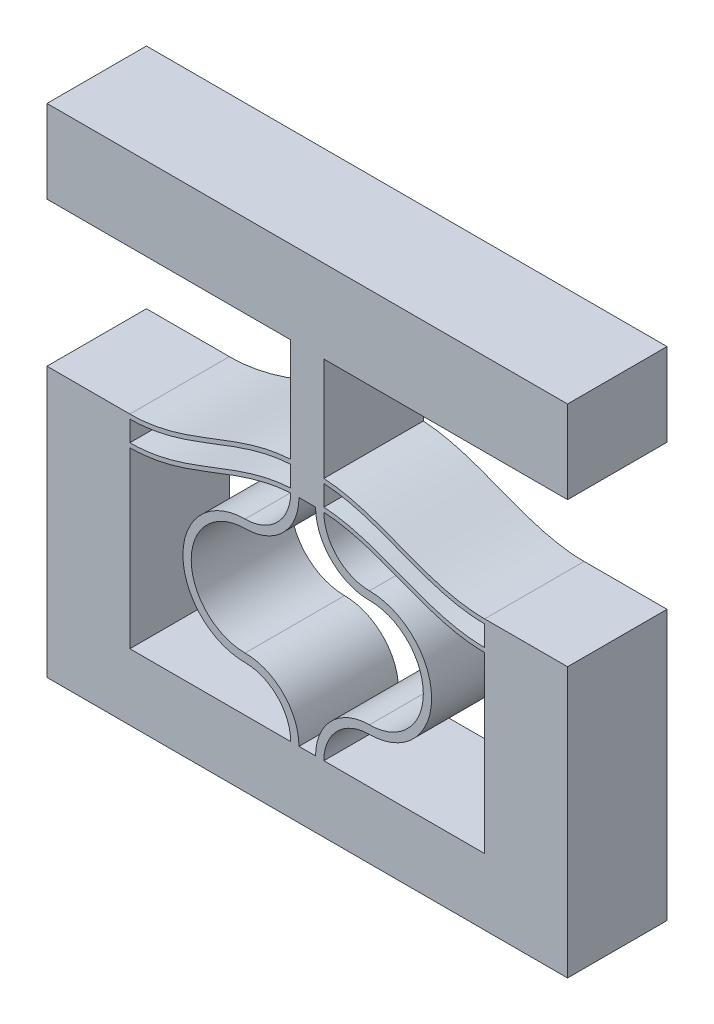
from build123d import *

# Parameters (mm, degrees)
BOSS_EXTRUDE1_DEPTH = 6
SKETCH4_W           = 1.000079602
SKETCH4_H           = 6
BOSS_EXTRUDE2_DEPTH = 5
SKETCH7_W           = 6
SKETCH7_H           = 7.985204536
SKETCH7_H_2         = 4
BOSS_EXTRUDE3_DEPTH = 0.5
SKETCH8_W           = 31.399999662
SKETCH8_H           = 5.000000005
BOSS_EXTRUDE4_DEPTH = 6


with BuildPart() as part:
    # Sketch1 → Boss-Extrude1 (new body)
    with BuildSketch(Plane.XY):
        with BuildLine():
            add(Edge.make_bspline(
                [(10.700039975, 14.745204536), (10.770772559, 14.741026808), (11.036928883, 14.722362813), (11.497122592, 14.671037325), (12.289279781, 14.528352814), (13.186428125, 14.281886639), (13.972953946, 14.012479628), (14.659814487, 13.755888369), (15.208666695, 13.545451258), (15.665563716, 13.368818224), (16.123450769, 13.194753096), (16.65208653, 13.002369042), (17.160327646, 12.828079612), (17.673887847, 12.669729106), (18.193716878, 12.533320658), (18.599888692, 12.444944264), (18.888931626, 12.391496574), (19.130919694, 12.353423685), (19.325052629, 12.327000657), (19.519580514, 12.304753805), (19.715757224, 12.286804034), (19.909026191, 12.273251391), (20.101721437, 12.264172749), (20.275673832, 12.260758352), (20.359000366, 12.259999604), (20.4, 12.259999604)],
                knots=[0.519813033, 0.519813033, 0.519813033, 0.519813033, 0.519813033, 0.531036625, 0.562073255, 0.593109869, 0.647173692, 0.678210339, 0.693728663, 0.709246987, 0.740283631, 0.755801952, 0.771320274, 0.79835218, 0.825384086, 0.84090241, 0.856420734, 0.86417989, 0.871939045, 0.8796982, 0.887457356, 0.89521651, 0.902975665, 0.910734819, 0.918493974, 0.918493974, 0.918493974, 0.918493974, 0.918493974], degree=4))
            Line((10.700039975, 14.745204536), (10.700039975, 15.985204536))
            Line((10.700039975, 15.985204536), (9.699960373, 15.985204536))
            Line((9.699960373, 15.985204536), (9.699960373, 14.745204536))
            add(Edge.make_bspline(
                [(0, 12.259999604), (0.040999634, 12.259999604), (0.124259479, 12.260758348), (0.355363371, 12.265310827), (0.583318983, 12.278545215), (0.832717182, 12.299192103), (1.123166493, 12.332562429), (1.414830156, 12.374284724), (1.752116289, 12.434526897), (2.206359313, 12.533321163), (2.726048123, 12.669728195), (3.239713703, 12.828081076), (3.7478924, 13.002367086), (4.184493287, 13.161250769), (4.551277809, 13.299188315), (4.917195343, 13.439475144), (5.282809261, 13.580521779), (5.740185056, 13.755889696), (6.427046416, 14.012478612), (7.213571652, 14.281887279), (8.110720324, 14.528352483), (8.902877469, 14.671037458), (9.363071278, 14.722362846), (9.629227699, 14.741026811), (9.699960373, 14.745204536)],
                knots=[0.081506026, 0.081506026, 0.081506026, 0.081506026, 0.081506026, 0.089265181, 0.097024335, 0.112542644, 0.1203018, 0.128060955, 0.143579266, 0.15909759, 0.174615914, 0.20164782, 0.228679726, 0.244198048, 0.259716369, 0.275234691, 0.290753013, 0.306271337, 0.321789661, 0.352826308, 0.406890131, 0.437926745, 0.468963375, 0.480186981, 0.480186981, 0.480186981, 0.480186981, 0.480186981], degree=4))
            Line((0, 12.259999604), (-5.000000005, 12.259999604))
            Line((-5.000000005, 12.259999604), (-5.000000005, -4))
            Line((-5.000000005, -4), (25.400000005, -4))
            Line((25.400000005, -4), (25.400000005, 12.259999604))
            Line((25.400000005, 12.259999604), (20.4, 12.259999604))
        make_face()
        with BuildLine():
            Line((9.699960373, 14.485204536), (9.699960373, 13.245204536))
            add(Edge.make_bspline(
                [(0, 10.759999604), (0.040999634, 10.759999604), (0.124259479, 10.760758348), (0.355363371, 10.765310827), (0.583318983, 10.778545215), (0.832717182, 10.799192103), (1.123166493, 10.832562429), (1.414830156, 10.874284724), (1.752116289, 10.934526897), (2.206359313, 11.033321163), (2.726048123, 11.169728195), (3.239713703, 11.328081076), (3.7478924, 11.502367086), (4.184493287, 11.661250769), (4.551277809, 11.799188315), (4.917195343, 11.939475144), (5.282809261, 12.080521779), (5.740185056, 12.255889696), (6.427046416, 12.512478612), (7.213571652, 12.781887279), (8.110720324, 13.028352483), (8.902877469, 13.171037458), (9.363071278, 13.222362846), (9.629227699, 13.241026811), (9.699960373, 13.245204536)],
                knots=[0.081506026, 0.081506026, 0.081506026, 0.081506026, 0.081506026, 0.089265181, 0.097024335, 0.112542644, 0.1203018, 0.128060955, 0.143579266, 0.15909759, 0.174615914, 0.20164782, 0.228679726, 0.244198048, 0.259716369, 0.275234691, 0.290753013, 0.306271337, 0.321789661, 0.352826308, 0.406890131, 0.437926745, 0.468963375, 0.480186981, 0.480186981, 0.480186981, 0.480186981, 0.480186981], degree=4))
            Line((0, 10.759999604), (0, 11.999999604))
            add(Edge.make_bspline(
                [(0, 11.999999604), (0.040999634, 11.999999604), (0.124259479, 12.000758348), (0.355363371, 12.005310827), (0.583318983, 12.018545215), (0.832717182, 12.039192103), (1.123166493, 12.072562429), (1.414830156, 12.114284724), (1.752116289, 12.174526897), (2.206359313, 12.273321163), (2.726048123, 12.409728195), (3.239713703, 12.568081076), (3.7478924, 12.742367086), (4.184493287, 12.901250769), (4.551277809, 13.039188315), (4.917195343, 13.179475144), (5.282809261, 13.320521779), (5.740185056, 13.495889696), (6.427046416, 13.752478612), (7.213571652, 14.021887279), (8.110720324, 14.268352483), (8.902877469, 14.411037458), (9.363071278, 14.462362846), (9.629227699, 14.481026811), (9.699960373, 14.485204536)],
                knots=[0.081506026, 0.081506026, 0.081506026, 0.081506026, 0.081506026, 0.089265181, 0.097024335, 0.112542644, 0.1203018, 0.128060955, 0.143579266, 0.15909759, 0.174615914, 0.20164782, 0.228679726, 0.244198048, 0.259716369, 0.275234691, 0.290753013, 0.306271337, 0.321789661, 0.352826308, 0.406890131, 0.437926745, 0.468963375, 0.480186981, 0.480186981, 0.480186981, 0.480186981, 0.480186981], degree=4))
        make_face(mode=Mode.SUBTRACT)
        with BuildLine():
            Line((10.700039975, 13.245204536), (10.700039975, 14.485204536))
            add(Edge.make_bspline(
                [(10.700039975, 14.485204536), (10.770772559, 14.481026808), (11.036928883, 14.462362813), (11.497122592, 14.411037325), (12.289279781, 14.268352814), (13.186428125, 14.021886639), (13.972953947, 13.752479628), (14.659814487, 13.495888369), (15.208666695, 13.285451258), (15.665563716, 13.108818224), (16.123450769, 12.934753096), (16.65208653, 12.742369042), (17.160327646, 12.568079612), (17.673887847, 12.409729106), (18.193716878, 12.273320658), (18.599888692, 12.184944264), (18.888931626, 12.131496574), (19.130919694, 12.093423685), (19.325052629, 12.067000657), (19.519580514, 12.044753805), (19.715757224, 12.026804034), (19.909026191, 12.013251391), (20.101721437, 12.004172749), (20.275673832, 12.000758352), (20.359000366, 11.999999604), (20.4, 11.999999604)],
                knots=[0.519813033, 0.519813033, 0.519813033, 0.519813033, 0.519813033, 0.531036625, 0.562073255, 0.593109869, 0.647173692, 0.678210339, 0.693728663, 0.709246987, 0.740283631, 0.755801952, 0.771320274, 0.79835218, 0.825384086, 0.84090241, 0.856420734, 0.86417989, 0.871939045, 0.8796982, 0.887457356, 0.89521651, 0.902975665, 0.910734819, 0.918493974, 0.918493974, 0.918493974, 0.918493974, 0.918493974], degree=4))
            Line((20.4, 11.999999604), (20.4, 10.759999604))
            add(Edge.make_bspline(
                [(10.700039975, 13.245204536), (10.770772559, 13.241026808), (11.036928883, 13.222362813), (11.497122592, 13.171037325), (12.289279781, 13.028352814), (13.186428125, 12.781886639), (13.972953947, 12.512479628), (14.659814487, 12.255888369), (15.208666695, 12.045451258), (15.665563716, 11.868818224), (16.123450769, 11.694753096), (16.65208653, 11.502369042), (17.160327646, 11.328079612), (17.673887847, 11.169729106), (18.193716878, 11.033320658), (18.599888692, 10.944944264), (18.888931626, 10.891496574), (19.130919694, 10.853423685), (19.325052629, 10.827000657), (19.519580514, 10.804753805), (19.715757224, 10.786804034), (19.909026191, 10.773251391), (20.101721437, 10.764172749), (20.275673832, 10.760758352), (20.359000366, 10.759999604), (20.4, 10.759999604)],
                knots=[0.519813033, 0.519813033, 0.519813033, 0.519813033, 0.519813033, 0.531036625, 0.562073255, 0.593109869, 0.647173692, 0.678210339, 0.693728663, 0.709246987, 0.740283631, 0.755801952, 0.771320274, 0.79835218, 0.825384086, 0.84090241, 0.856420734, 0.86417989, 0.871939045, 0.8796982, 0.887457356, 0.89521651, 0.902975665, 0.910734819, 0.918493974, 0.918493974, 0.918493974, 0.918493974, 0.918493974], degree=4))
        make_face(mode=Mode.SUBTRACT)
        with BuildLine():
            Line((0, 0), (0, 10.499999604))
            add(Edge.make_bspline(
                [(0, 10.499999604), (0.040999634, 10.499999604), (0.124259479, 10.500758348), (0.355363371, 10.505310827), (0.583318983, 10.518545215), (0.832717182, 10.539192103), (1.123166493, 10.572562429), (1.414830156, 10.614284724), (1.752116289, 10.674526897), (2.206359313, 10.773321163), (2.726048123, 10.909728195), (3.239713703, 11.068081076), (3.7478924, 11.242367086), (4.184493287, 11.401250769), (4.551277809, 11.539188315), (4.917195343, 11.679475144), (5.282809261, 11.820521779), (5.740185056, 11.995889696), (6.427046416, 12.252478612), (7.213571652, 12.521887279), (8.110720324, 12.768352483), (8.902877469, 12.911037458), (9.363071278, 12.962362846), (9.629227699, 12.981026811), (9.699960373, 12.985204536)],
                knots=[0.081506026, 0.081506026, 0.081506026, 0.081506026, 0.081506026, 0.089265181, 0.097024335, 0.112542644, 0.1203018, 0.128060955, 0.143579266, 0.15909759, 0.174615914, 0.20164782, 0.228679726, 0.244198048, 0.259716369, 0.275234691, 0.290753013, 0.306271337, 0.321789661, 0.352826308, 0.406890131, 0.437926745, 0.468963375, 0.480186981, 0.480186981, 0.480186981, 0.480186981, 0.480186981], degree=4))
            ThreePointArc((9.699960373, 12.985204536), (8.889305781, 11.050232382), (6.950000174, 10.25))
            ThreePointArc((6.950000174, 10.25), (3.200000174, 6.5), (6.950000174, 2.75))
            ThreePointArc((6.950000174, 2.75), (8.894543822, 1.944543648), (9.700000174, 0))
            Line((9.700000174, 0), (0, 0))
        make_face(mode=Mode.SUBTRACT)
        with BuildLine():
            ThreePointArc((6.950000174, 9.75), (9.248097213, 10.701902961), (10.200000174, 13))
            ThreePointArc((10.200000174, 13), (11.151903135, 10.701902961), (13.450000174, 9.75))
            ThreePointArc((13.450000174, 9.75), (16.700000174, 6.5), (13.450000174, 3.25))
            ThreePointArc((13.450000174, 3.25), (11.151903135, 2.298097039), (10.200000174, 0))
            ThreePointArc((10.200000174, 0), (9.248097213, 2.298097039), (6.950000174, 3.25))
            ThreePointArc((6.950000174, 3.25), (3.700000174, 6.5), (6.950000174, 9.75))
        make_face(mode=Mode.SUBTRACT)
        with BuildLine():
            ThreePointArc((13.450000174, 10.25), (11.510694567, 11.050232382), (10.700039975, 12.985204536))
            add(Edge.make_bspline(
                [(10.700039975, 12.985204536), (10.770772559, 12.981026808), (11.036928883, 12.962362813), (11.497122592, 12.911037325), (12.289279781, 12.768352814), (13.186428125, 12.521886639), (13.972953947, 12.252479628), (14.659814487, 11.995888369), (15.208666695, 11.785451258), (15.665563716, 11.608818224), (16.123450769, 11.434753096), (16.65208653, 11.242369042), (17.160327646, 11.068079612), (17.673887847, 10.909729106), (18.193716878, 10.773320658), (18.599888692, 10.684944264), (18.888931626, 10.631496574), (19.130919694, 10.593423685), (19.325052629, 10.567000657), (19.519580514, 10.544753805), (19.715757224, 10.526804034), (19.909026191, 10.513251391), (20.101721437, 10.504172749), (20.275673832, 10.500758352), (20.359000366, 10.499999604), (20.4, 10.499999604)],
                knots=[0.519813033, 0.519813033, 0.519813033, 0.519813033, 0.519813033, 0.531036625, 0.562073255, 0.593109869, 0.647173692, 0.678210339, 0.693728663, 0.709246987, 0.740283631, 0.755801952, 0.771320274, 0.79835218, 0.825384086, 0.84090241, 0.856420734, 0.86417989, 0.871939045, 0.8796982, 0.887457356, 0.89521651, 0.902975665, 0.910734819, 0.918493974, 0.918493974, 0.918493974, 0.918493974, 0.918493974], degree=4))
            Line((20.4, 10.499999604), (20.4, 0))
            Line((20.4, 0), (10.700000174, 0))
            ThreePointArc((10.700000174, 0), (11.505456526, 1.944543648), (13.450000174, 2.75))
            ThreePointArc((13.450000174, 2.75), (17.200000174, 6.5), (13.450000174, 10.25))
        make_face(mode=Mode.SUBTRACT)
    extrude(amount=BOSS_EXTRUDE1_DEPTH)

    # Sketch4 → Boss-Extrude2 (add)
    with BuildSketch(Plane(origin=(0, 15.985204536, 0), x_dir=(1, 0, 0), z_dir=(0, 1, 0))):
        with Locations((10.200000174, -3)):
            Rectangle(SKETCH4_W, SKETCH4_H)
    extrude(amount=BOSS_EXTRUDE2_DEPTH)

    # Split2
    split(bisect_by=Plane(origin=(10.200000174, 0, 0), x_dir=(0, -1, 0), z_dir=(-1, 0, 0)), keep=Keep.BOTTOM)

    # Sketch7 → Boss-Extrude3 (add)
    with BuildSketch(Plane.ZY.offset(-10.200000174)):
        with Locations((3, 16.992602268)):
            Rectangle(SKETCH7_W, SKETCH7_H)
        with Locations((3, -2)):
            Rectangle(SKETCH7_W, SKETCH7_H_2)
    extrude(amount=BOSS_EXTRUDE3_DEPTH)

    # Mirror2: part across plane


with BuildPart() as part_1:
    add(part.part)
    add(part.part.mirror(Plane.ZY.offset(-9.700000174)))

    # Sketch8 → Boss-Extrude4 (add)
    with BuildSketch(Plane.XY.offset(6)):
        with Locations((9.700000174, 23.485204538)):
            Rectangle(SKETCH8_W, SKETCH8_H)
    extrude(amount=-BOSS_EXTRUDE4_DEPTH)


solid = part_1.part
